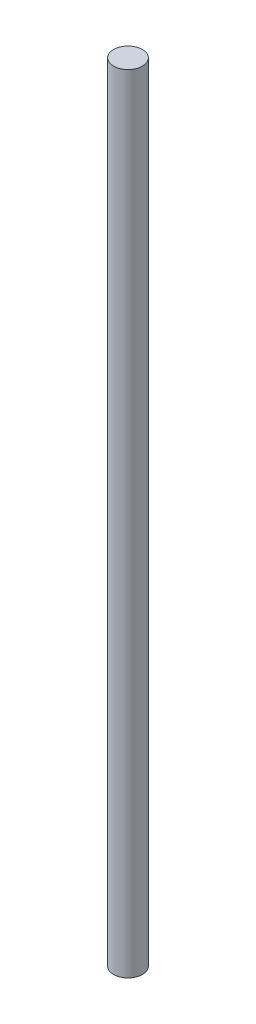
from build123d import *

# Parameters (mm, degrees)
SKETCH1_R           = 11
BOSS_EXTRUDE1_DEPTH = 600


with BuildPart() as part:
    # Sketch1 → Boss-Extrude1 (new body)
    with BuildSketch(Plane(origin=(0, 0, 0), x_dir=(1, 0, 0), z_dir=(0, 1, 0))):
        Circle(SKETCH1_R)
    extrude(amount=BOSS_EXTRUDE1_DEPTH)


solid = part.part
